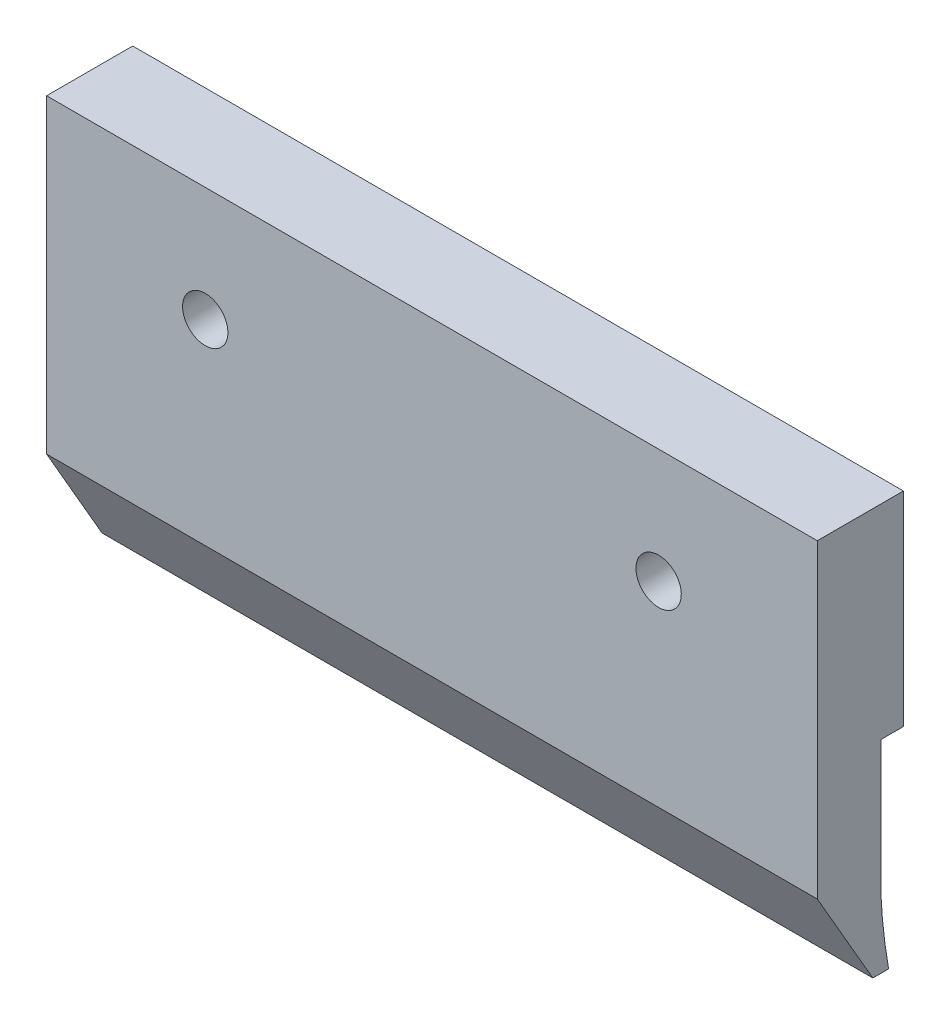
from build123d import *

# Parameters (mm, degrees)
BOSS_EXTRUDE1_DEPTH      = 17
BOSS_EXTRUDE1_DEPTH_BACK = 17
SKETCH4_R                = 1
CUT_EXTRUDE1_DEPTH       = 17


with BuildPart() as part:
    # Sketch1 → Boss-Extrude1 (new, two sides: drawn at the far end of the back side and taken through both)
    with BuildSketch(Plane(origin=(0, 0, 0), x_dir=(0, 0, -1), z_dir=(1, 0, 0)).offset(-BOSS_EXTRUDE1_DEPTH_BACK)):
        with BuildLine():
            Line((0, 0), (1, 0))
            Line((1, 0), (1, 9))
            Line((1, 9), (-2.8, 9))
            Line((-2.8, 9), (-2.8, 0))
            Line((-2.8, 0), (-2.8, -4.689169104))
            Line((-2.8, -4.689169104), (-0.351186116, -8.93063917))
            Line((-0.351186116, -8.93063917), (0, -8.93063917))
            Line((0, -8.93063917), (0.3465, -8.93063917))
            add(Edge.make_bspline(
                [(0, -5.784861062), (0.068127357, -7.369329156), (0.3465, -8.93063917)],
                knots=[0, 0, 0, 1, 1, 1], degree=2))
            Line((0, -5.784861062), (0, 0))
        make_face()
    extrude(amount=BOSS_EXTRUDE1_DEPTH + BOSS_EXTRUDE1_DEPTH_BACK)

    # Sketch4 → Cut-Extrude1 (cut)
    with BuildSketch(Plane(origin=(0, 0, -1), x_dir=(-1, 0, 0), z_dir=(0, 0, -1))):
        with Locations((-10, 3.95)):
            Circle(SKETCH4_R)
        with Locations((10, 3.95)):
            Circle(SKETCH4_R)
    extrude(amount=-CUT_EXTRUDE1_DEPTH, mode=Mode.SUBTRACT)


solid = part.part
